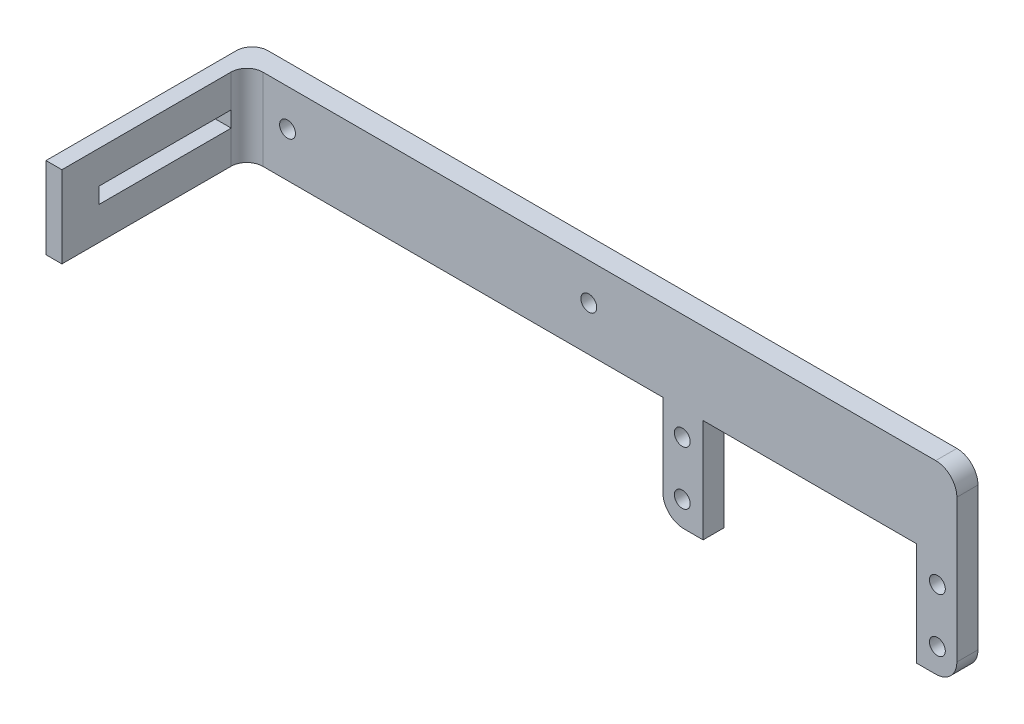
from build123d import *

# Parameters (mm, degrees)
BOSS_EXTRUDE2_DEPTH     = 4
FILLET1_R               = 4
SKETCH6_R               = 1.5
CUT_EXTRUDE1_DEPTH      = 4
SKETCH3_R               = 1.5
CUT_EXTRUDE2_DEPTH      = 4
SKETCH7_W               = 3.00651588
SKETCH7_H               = 15.442
BOSS_EXTRUDE3_DEPTH     = 35
FILLET2_R               = 3
FILLET3_R               = 3
SKETCH8_W               = 25
SKETCH8_H               = 3
CUT_EXTRUDE6_DEPTH      = 4
CUT_EXTRUDE6_DEPTH_BACK = 4


with BuildPart() as part:
    # Sketch2 → Boss-Extrude2 (new body)
    with BuildSketch(Plane.XY):
        Polygon((-67.081093968, -2.634474623), (-67.081093968, 16.923525377), (-26.695093968, 16.923525377), (-26.695093968, -2.634474623), (-19.075093968, -2.634474623), (-19.075093968, 32.365525377), (-67.081093968, 32.365525377), (-74.701093968, 32.365525377), (-156.39106061, 32.365525377), (-156.39106061, 16.923525377), (-74.701093968, 16.923525377), (-74.701093968, -2.634474623), align=None)
    extrude(amount=BOSS_EXTRUDE2_DEPTH)

    # Fillet1
    fillet1_edges = [part.edges().sort_by_distance(p)[0] for p in [
        (-19.075093968, 32.365525377, 2),
        (-19.075093968, -2.634474623, 2),
        (-74.701093968, -2.634474623, 2),
    ]]
    fillet(fillet1_edges, radius=FILLET1_R)

    # Sketch6 → Cut-Extrude1 (cut)
    with BuildSketch(Plane.XY.offset(4)):
        with Locations((-71.018093968, 12.224525377)):
            Circle(SKETCH6_R)
        with Locations((-22.758093968, 12.224525377)):
            Circle(SKETCH6_R)
        with Locations((-22.758093968, 2.064525377)):
            Circle(SKETCH6_R)
        with Locations((-71.018093968, 2.064525377)):
            Circle(SKETCH6_R)
    extrude(amount=-CUT_EXTRUDE1_DEPTH, mode=Mode.SUBTRACT)

    # Sketch3 → Cut-Extrude2 (cut)
    with BuildSketch(Plane.XY.offset(4)):
        with Locations((-145.701093968, 25.365525377)):
            Circle(SKETCH3_R)
        with Locations((-88.701093968, 25.365525377)):
            Circle(SKETCH3_R)
    extrude(amount=-CUT_EXTRUDE2_DEPTH, mode=Mode.SUBTRACT)

    # Sketch7 → Boss-Extrude3 (add)
    with BuildSketch(Plane.XY.offset(4)):
        with Locations((-154.88780267, 24.644525377)):
            Rectangle(SKETCH7_W, SKETCH7_H)
    extrude(amount=BOSS_EXTRUDE3_DEPTH)

    # Fillet2
    fillet2_edges = [part.edges().sort_by_distance(p)[0] for p in [
        (-153.38454473, 24.644525377, 4),
    ]]
    fillet(fillet2_edges, radius=FILLET2_R)

    # Fillet3
    fillet3_edges = [part.edges().sort_by_distance(p)[0] for p in [
        (-156.39106061, 24.644525377, 0),
    ]]
    fillet(fillet3_edges, radius=FILLET3_R)

    # Sketch8 → Cut-Extrude6 (cut, two sides)
    with BuildSketch(Plane.ZY.offset(156.39106061)) as cut_extrude6_sk:
        with Locations((19.4669967, 24.665525377)):
            Rectangle(SKETCH8_W, SKETCH8_H)
    extrude(amount=CUT_EXTRUDE6_DEPTH, mode=Mode.SUBTRACT)
    extrude(cut_extrude6_sk.sketch, amount=-CUT_EXTRUDE6_DEPTH_BACK, mode=Mode.SUBTRACT)


solid = part.part
